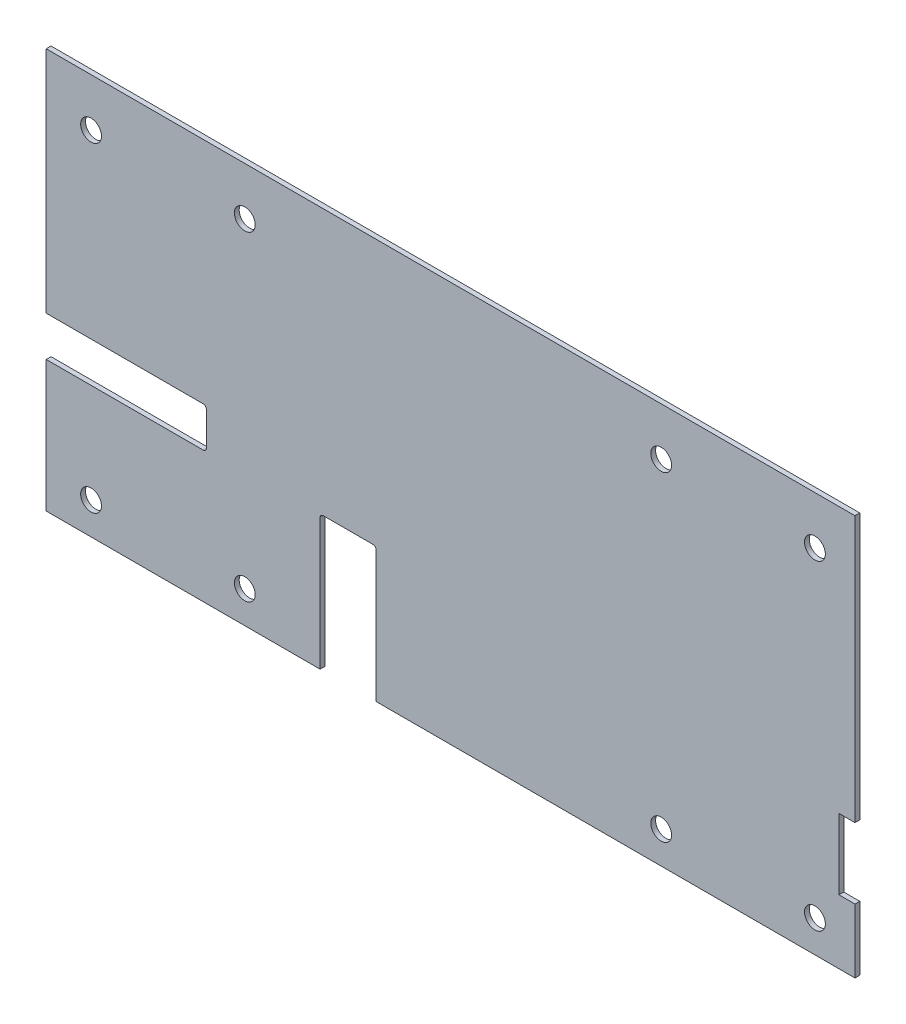
from build123d import *

# Parameters (mm, degrees)
ESQUISSE1_W             = 505
ESQUISSE1_H             = 250
ESQUISSE1_R             = 6.5
BOSS_EXTRU_1_DEPTH      = 3
ESQUISSE4_W             = 100
ESQUISSE4_H             = 25
ESQUISSE4_W_2           = 35
ESQUISSE4_H_2           = 84
ESQUISSE4_W_3           = 10
ESQUISSE4_H_3           = 44
ENL_V_MAT_EXTRU_3_DEPTH = 10
CONG_1_R                = 2


with BuildPart() as part:
    # Esquisse1 → Boss.-Extru.1 (new body)
    with BuildSketch(Plane.XY):
        Rectangle(ESQUISSE1_W, ESQUISSE1_H)
        with Locations((131.5, 95)):
            Circle(ESQUISSE1_R, mode=Mode.SUBTRACT)
        with Locations((227.5, 95)):
            Circle(ESQUISSE1_R, mode=Mode.SUBTRACT)
        with Locations((131.5, -105)):
            Circle(ESQUISSE1_R, mode=Mode.SUBTRACT)
        with Locations((227.5, -105)):
            Circle(ESQUISSE1_R, mode=Mode.SUBTRACT)
        with Locations((-128.5, -105)):
            Circle(ESQUISSE1_R, mode=Mode.SUBTRACT)
        with Locations((-128.5, 95)):
            Circle(ESQUISSE1_R, mode=Mode.SUBTRACT)
        with Locations((-224.5, 95)):
            Circle(ESQUISSE1_R, mode=Mode.SUBTRACT)
        with Locations((-224.5, -105)):
            Circle(ESQUISSE1_R, mode=Mode.SUBTRACT)
    extrude(amount=BOSS_EXTRU_1_DEPTH)

    # Esquisse4 → Enlèv. mat.-Extru.3 (cut)
    with BuildSketch(Plane.XY.offset(3)):
        with Locations((-202.5, -30.5)):
            Rectangle(ESQUISSE4_W, ESQUISSE4_H)
        with Locations((-64, -83)):
            Rectangle(ESQUISSE4_W_2, ESQUISSE4_H_2)
        with Locations((247.5, -63)):
            Rectangle(ESQUISSE4_W_3, ESQUISSE4_H_3)
    extrude(amount=-ENL_V_MAT_EXTRU_3_DEPTH, mode=Mode.SUBTRACT)

    # Congé1
    cong_1_edges = [part.edges().sort_by_distance(p)[0] for p in [
        (-152.5, -18, 1.5),
        (-152.5, -43, 1.5),
        (-81.5, -41, 1.5),
        (-46.5, -41, 1.5),
    ]]
    fillet(cong_1_edges, radius=CONG_1_R)


solid = part.part
